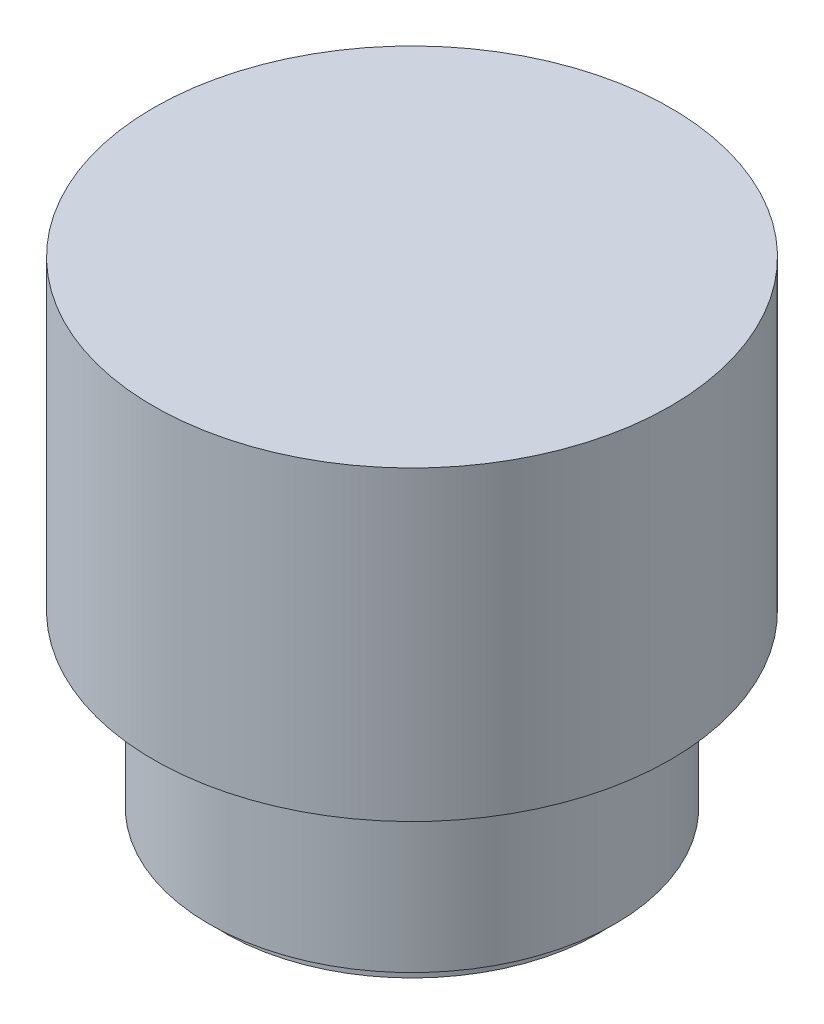
from build123d import *

# Parameters (mm, degrees)
SKETCH3_R          = 1.25
CUT_EXTRUDE1_DEPTH = 8


with BuildPart() as part:
    # Sketch1 → Revolve1 (revolve)
    with BuildSketch(Plane.XY):
        Polygon((0, 0), (-23.5, 0), (-23.5, 2), (-25.5, 2), (-25.5, 23.4), (-32.5, 23.4), (-32.5, 61.9), (0, 61.9), align=None)
    revolve(axis=Axis((0, -426.088089194, 0), (0, 1, 0)))

    # Sketch2 → Cut-Revolve1 (revolve, cut)
    with BuildSketch(Plane(origin=(0, 41.5, 0), x_dir=(-1, 0, 0), z_dir=(0, -1, 0))):
        Polygon((-19.929871148, 32.5), (-19.85, 14.194997457), (-13.5, 14.194997457), (-13.5, 32.5), align=None)
    cut_revolve1 = revolve(axis=Axis((13.5, 41.5, 985.805002543), (0, 0, -1)), mode=Mode.SUBTRACT)

    # Mirror1: Cut-Revolve1 across plane
    add(cut_revolve1.mirror(Plane(origin=(0, 0, 0), x_dir=(0, 0, 1), z_dir=(1, 0, 0))), mode=Mode.SUBTRACT)

    # Sketch3 → Cut-Extrude1 (cut)
    with BuildSketch(Plane.XZ):
        with Locations((-15, 15)):
            Circle(SKETCH3_R)
        with Locations((-15, -15)):
            Circle(SKETCH3_R)
        with Locations((15, -15)):
            Circle(SKETCH3_R)
        with Locations((15, 15)):
            Circle(SKETCH3_R)
    extrude(amount=-CUT_EXTRUDE1_DEPTH, mode=Mode.SUBTRACT)


solid = part.part
